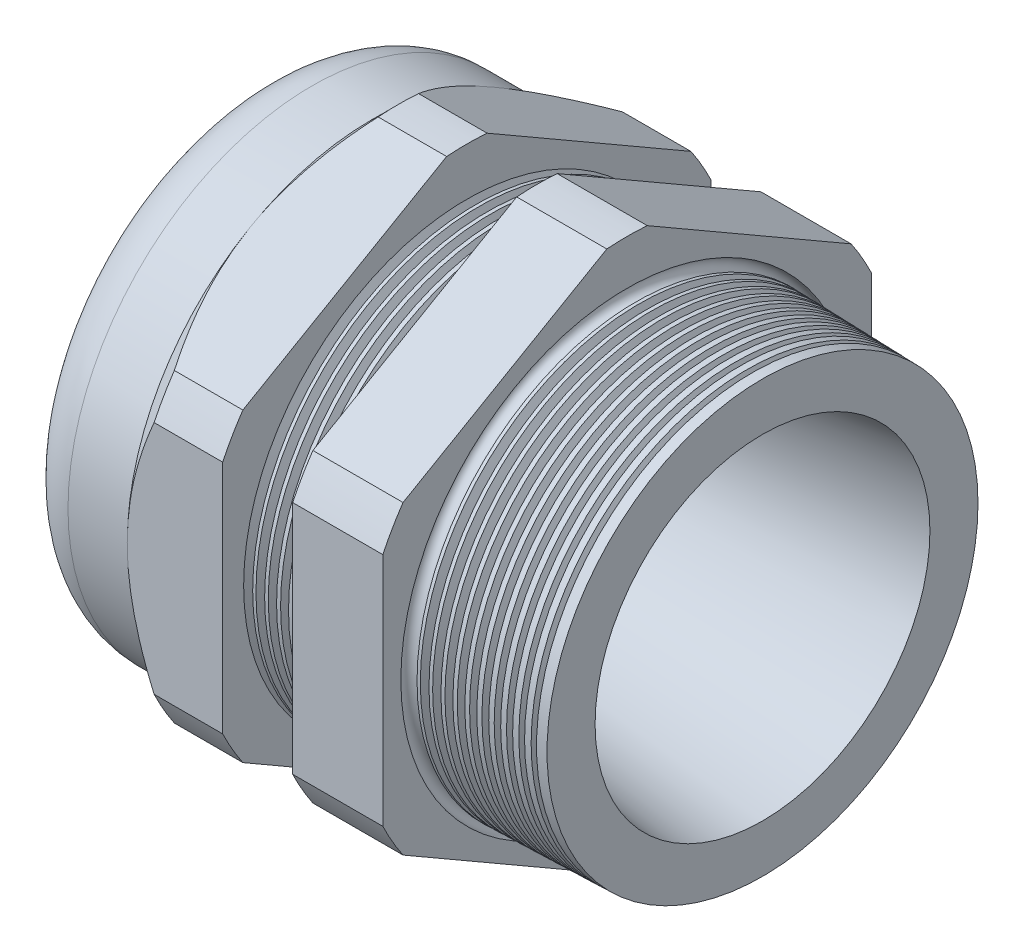
from build123d import *

# Parameters (mm, degrees)
LPATTERN6_COUNT    = 6
LPATTERN6_PITCH    = 1.5748
LPATTERN7_COUNT    = 11
LPATTERN7_PITCH    = 1.5748
SKETCH12_OUTSIDE_W = 171.2
SKETCH12_OUTSIDE_H = 171.2
CUT_EXTRUDE2_DEPTH = 53.05603
FILLET4_R          = 7.112
SKETCH19_OUTSIDE_W = 98.628
SKETCH19_OUTSIDE_H = 105.78
SKETCH19_OUTSIDE_R = 32.512
CUT_EXTRUDE3_DEPTH = 3.99796
CUT_EXTRUDE3_DRAFT = -45
SKETCH28_R         = 1.0795


with BuildPart() as part:
    # Sketch10 → Revolve2 (revolve)
    with BuildSketch(Plane.XY, mode=Mode.PRIVATE) as revolve2_sk:
        Polygon((-41.89603, 17.526), (-29.19603, 17.526), (10.16, 22.2885), (10.16, 28.687426085), (-7.874, 29.159662995), (-7.874, 65.024), (-19.873976, 65.024), (-19.873976, 29.473893425), (-29.19603, 29.718), (-29.19603, 65.024), (-41.89603, 65.024), (-41.89603, 32.512), (-56.896, 32.512), (-56.896, 22.2885), (-41.89603, 22.2885), align=None)
    revolve(revolve2_sk.sketch.rotate(Axis((0, 0, 0), (-1, 0, 0)), 90), axis=Axis((0, 0, 0), (-1, 0, 0)))  # turned: the seam where the file's is

    # Sketch26 → Cut-Revolve1 (revolve, cut)
    with BuildSketch(Plane.XY, mode=Mode.PRIVATE) as cut_revolve1_sk:
        Polygon((-29.19603, 29.718), (-28.023256271, 29.687289839), (-28.636238915, 28.686993077), align=None)
    cut_revolve1 = revolve(cut_revolve1_sk.sketch.rotate(Axis((0, 0, 0), (-1, 0, 0)), 90), axis=Axis((0, 0, 0), (-1, 0, 0)), mode=Mode.SUBTRACT)  # turned: the seam where the file's is

    # LPattern6: Cut-Revolve1 ×6
    with Locations(*[(i * LPATTERN6_PITCH, 0, 0) for i in range(1, LPATTERN6_COUNT)]):
        add(cut_revolve1, mode=Mode.SUBTRACT)

    # Sketch27 → Cut-Revolve2 (revolve, cut)
    with BuildSketch(Plane.XY, mode=Mode.PRIVATE) as cut_revolve2_sk:
        Polygon((-7.874, 29.159662995), (-6.701226271, 29.128952834), (-7.314208915, 28.128656072), align=None)
    cut_revolve2 = revolve(cut_revolve2_sk.sketch.rotate(Axis((0, 0, 0), (-1, 0, 0)), 90), axis=Axis((0, 0, 0), (-1, 0, 0)), mode=Mode.SUBTRACT)  # turned: the seam where the file's is

    # LPattern7: Cut-Revolve2 ×11
    with Locations(*[(i * LPATTERN7_PITCH, 0, 0) for i in range(1, LPATTERN7_COUNT)]):
        add(cut_revolve2, mode=Mode.SUBTRACT)

    # Sketch12 outside → Cut-Extrude2 (cut, through all)
    with BuildSketch(Plane.ZY.offset(41.89603)):
        Rectangle(SKETCH12_OUTSIDE_W, SKETCH12_OUTSIDE_H)
        with BuildLine():
            Line((-2.69124706, 35.987831689), (-29.82075294, 20.324604167))
            ThreePointArc((-29.82075294, 20.324604167), (-31.2534019, 18.04416), (-32.512, 15.663227523))
            Line((-32.512, 15.663227523), (-32.512, -15.663227523))
            ThreePointArc((-32.512, -15.663227523), (-31.2534019, -18.04416), (-29.82075294, -20.324604167))
            Line((-29.82075294, -20.324604167), (-2.69124706, -35.987831689))
            ThreePointArc((-2.69124706, -35.987831689), (0, -36.08832), (2.69124706, -35.987831689))
            Line((2.69124706, -35.987831689), (29.82075294, -20.324604167))
            ThreePointArc((29.82075294, -20.324604167), (31.2534019, -18.04416), (32.512, -15.663227523))
            Line((32.512, -15.663227523), (32.512, 15.663227523))
            ThreePointArc((32.512, 15.663227523), (31.2534019, 18.04416), (29.82075294, 20.324604167))
            Line((29.82075294, 20.324604167), (2.69124706, 35.987831689))
            ThreePointArc((2.69124706, 35.987831689), (0, 36.08832), (-2.69124706, 35.987831689))
        make_face(mode=Mode.SUBTRACT)
    extrude(amount=-CUT_EXTRUDE2_DEPTH, mode=Mode.SUBTRACT)

    # Fillet4
    fillet4_edges = [part.edges().sort_by_distance(p)[0] for p in [
        (-56.896, 0, 32.512),
    ]]
    fillet(fillet4_edges, radius=FILLET4_R)


with BuildPart() as body_2:
    # Sketch30 → Revolve8 (revolve)
    with BuildSketch(Plane.XY, mode=Mode.PRIVATE) as revolve8_sk:
        with BuildLine():
            Line((-55.9054, 22.2885), (-41.89603, 22.2885))
            Line((-41.89603, 22.2885), (-41.89603, 17.526))
            Line((-41.89603, 17.526), (-56.134, 17.526))
            Line((-56.134, 17.526), (-56.134, 22.0599))
            ThreePointArc((-56.134, 22.0599), (-56.06704461, 22.22154461), (-55.9054, 22.2885))
        make_face()
    revolve(revolve8_sk.sketch.rotate(Axis((0, 0, 0), (-1, 0, 0)), 270), axis=Axis((0, 0, 0), (-1, 0, 0)))  # turned: the seam where the file's is


with BuildPart() as cut_extrude3_tool:
    # Sketch19 outside → Cut-Extrude3 (with draft: the straight prism first)
    with BuildSketch(Plane.ZY.offset(41.89603)):
        Rectangle(SKETCH19_OUTSIDE_W, SKETCH19_OUTSIDE_H)
        Circle(SKETCH19_OUTSIDE_R, mode=Mode.SUBTRACT)
    extrude(amount=-CUT_EXTRUDE3_DEPTH)
    # Cut-Extrude3: the draft: its side faces are tilted about the plane it starts from
    cut_extrude3_sides = [cut_extrude3_tool.faces().sort_by_distance(p)[0] for p in [
        (-39.89705, -52.89, 0),
        (-39.89705, 0, 49.314),
        (-39.89705, 52.89, 0),
        (-39.89705, 0, -49.314),
        (-39.89705, 0, -32.512),
    ]]
    draft(cut_extrude3_sides, Plane.ZY.offset(41.89603), CUT_EXTRUDE3_DRAFT)


with BuildPart() as part_1:
    add(part.part)

    # Cut-Extrude3: cut by cut_extrude3_tool
    add(cut_extrude3_tool.part, mode=Mode.SUBTRACT)

    # Sketch28 → Cut-Revolve3 (revolve, cut)
    with BuildSketch(Plane.XY, mode=Mode.PRIVATE) as cut_revolve3_sk:
        with Locations((-7.8486, -29.032662995)):
            Circle(SKETCH28_R)
    revolve(cut_revolve3_sk.sketch.rotate(Axis((10.16, 0, 0), (-1, 0, 0)), 90), axis=Axis((10.16, 0, 0), (-1, 0, 0)), mode=Mode.SUBTRACT)  # turned: the seam where the file's is


solid = Compound([body_2.part, part_1.part])
